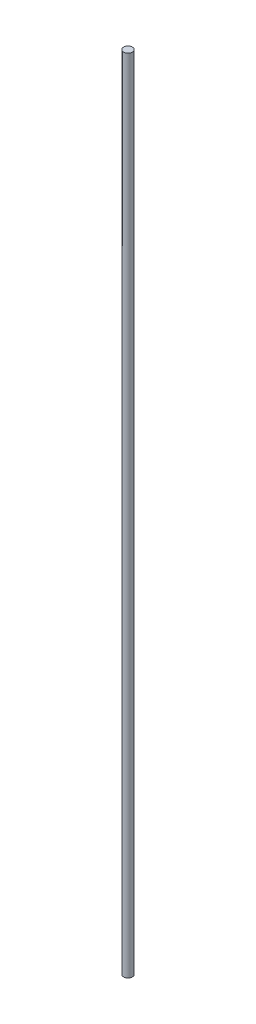
from build123d import *

# Parameters (mm, degrees)
SKETCH1_R           = 0.95
BOSS_EXTRUDE1_DEPTH = 173


with BuildPart() as part:
    # Sketch1 → Boss-Extrude1 (new body)
    with BuildSketch(Plane(origin=(0, 0, 0), x_dir=(1, 0, 0), z_dir=(0, 1, 0))):
        Circle(SKETCH1_R)
    extrude(amount=BOSS_EXTRUDE1_DEPTH)


solid = part.part
